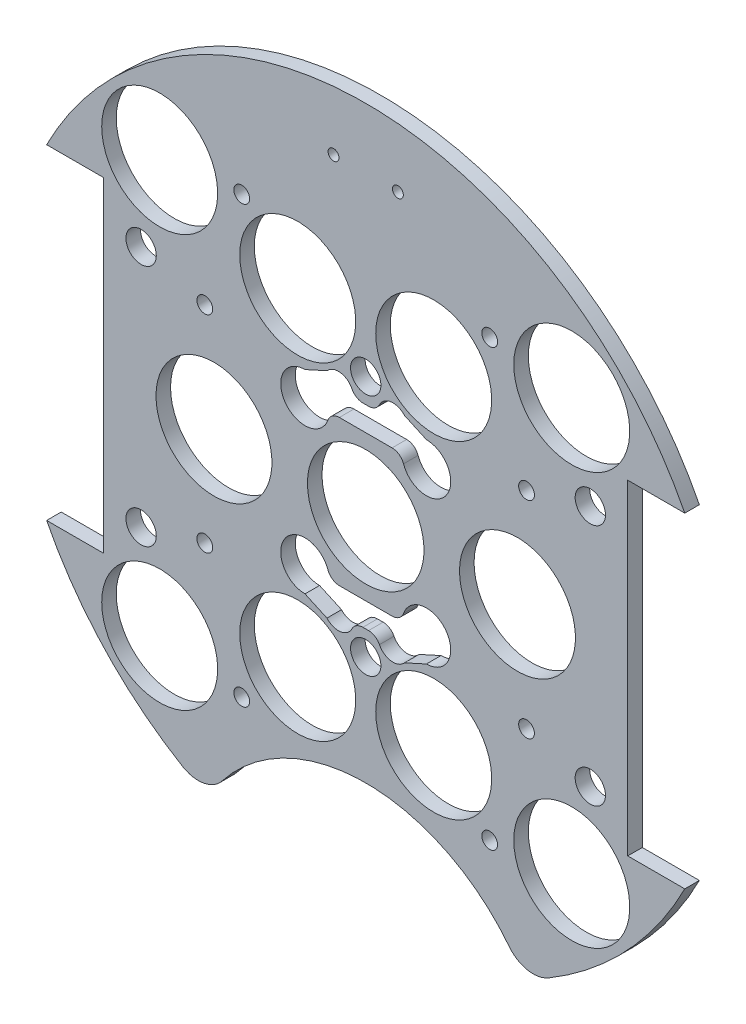
from build123d import *

# Parameters (mm, degrees)
BOSS_EXTRUDE2_DEPTH      = 3.048
SKETCH2_R                = 1.143
CUT_EXTRUDE1_DEPTH       = 101.398460187
SKETCH4_R                = 38.1
CUT_EXTRUDE3_DEPTH       = 124.46
FILLET1_R                = 6.35
SKETCH12_R               = 1.651
CUT_EXTRUDE11_DEPTH      = 75.692
SKETCH14_R               = 1.651
CUT_EXTRUDE13_DEPTH      = 97.79
SKETCH15_R               = 3.175
CUT_EXTRUDE14_DEPTH      = 103.378
CUT_EXTRUDE14_DEPTH_BACK = 48.768
SKETCH3_R                = 12.1285
SKETCH3_R_2              = 12.192
CUT_EXTRUDE2_DEPTH       = 101.398460332
FILLET2_R                = 2.54


with BuildPart() as part:
    # Sketch1 → Boss-Extrude2 (new body)
    with BuildSketch(Plane.XY):
        with BuildLine():
            Line((-66.753693561, 34.036), (-54.815693561, 34.036))
            Line((-54.815693561, 34.036), (-54.815693561, -34.036))
            Line((-54.815693561, -34.036), (-66.753693561, -34.036))
            ThreePointArc((-66.753693561, -34.036), (0, -74.93), (66.753693561, -34.036))
            Line((66.753693561, -34.036), (54.815693561, -34.036))
            Line((54.815693561, -34.036), (54.815693561, 34.036))
            Line((54.815693561, 34.036), (66.753693561, 34.036))
            ThreePointArc((66.753693561, 34.036), (0, 74.93), (-66.753693561, 34.036))
        make_face()
    extrude(amount=BOSS_EXTRUDE2_DEPTH)

    # Sketch2 → Cut-Extrude1 (cut, through all)
    with BuildSketch(Plane.XY.offset(3.048)):
        with Locations((-6.731, 62.23)):
            Circle(SKETCH2_R)
        with Locations((6.731, 62.23)):
            Circle(SKETCH2_R)
    extrude(amount=-CUT_EXTRUDE1_DEPTH, mode=Mode.SUBTRACT)

    # Sketch4 → Cut-Extrude3 (cut)
    with BuildSketch(Plane(origin=(0, 0, 0), x_dir=(-1, 0, 0), z_dir=(0, 0, -1))):
        with Locations((0, -86.312058398)):
            Circle(SKETCH4_R)
    extrude(amount=-CUT_EXTRUDE3_DEPTH, mode=Mode.SUBTRACT)

    # Fillet1
    fillet1_edges = [part.edges().sort_by_distance(p)[0] for p in [
        (-33.000960548, -67.271401821, 1.524),
        (33.000960548, -67.271401821, 1.524),
    ]]
    fillet(fillet1_edges, radius=FILLET1_R)

    # Sketch12 → Cut-Extrude11 (cut)
    with BuildSketch(Plane(origin=(30.092005081, 4.08352975, 0), x_dir=(-1, 0, 0), z_dir=(0, 0, -1))):
        with Locations((63.757223581, 17.50647025)):
            Circle(SKETCH12_R)
        with Locations((63.757223581, -25.67352975)):
            Circle(SKETCH12_R)
        with Locations((-3.552776419, -25.67352975)):
            Circle(SKETCH12_R)
        with Locations((-3.552776419, 17.50647025)):
            Circle(SKETCH12_R)
    extrude(amount=-CUT_EXTRUDE11_DEPTH, mode=Mode.SUBTRACT)

    # Sketch14 → Cut-Extrude13 (cut)
    with BuildSketch(Plane(origin=(30.092005081, 4.08352975, -30.0355), x_dir=(-1, 0, 0), z_dir=(0, 0, -1))):
        with Locations(Location((4.154396091, -49.728759131, 0), (0, 0, 180))):
            Circle(SKETCH14_R)
        with Locations(Location((56.02961407, -49.728759131, 0), (0, 0, 180))):
            Circle(SKETCH14_R)
        with Locations(Location((4.154396091, 41.38247025, 0), (0, 0, 180))):
            Circle(SKETCH14_R)
        with Locations(Location((56.02961407, 41.38247025, 0), (0, 0, 180))):
            Circle(SKETCH14_R)
    extrude(amount=-CUT_EXTRUDE13_DEPTH, mode=Mode.SUBTRACT)

    # Sketch15 → Cut-Extrude14 (cut, two sides)
    with BuildSketch(Plane(origin=(30.092005081, 4.08352975, 6.096), x_dir=(-1, 0, 0), z_dir=(0, 0, -1))) as cut_extrude14_sk:
        with Locations(Location((-16.897994919, 21.31647025, 0), (0, 0, 180))):
            Circle(SKETCH15_R)
        with Locations(Location((77.082005081, 21.31647025, 0), (0, 0, 180))):
            Circle(SKETCH15_R)
        with Locations(Location((30.092005081, 21.31647025, 0), (0, 0, 180))):
            Circle(SKETCH15_R)
        with Locations(Location((77.082005081, -29.48352975, 0), (0, 0, 180))):
            Circle(SKETCH15_R)
        with Locations(Location((30.092005081, -29.48352975, 0), (0, 0, 180))):
            Circle(SKETCH15_R)
        with Locations(Location((-16.897994919, -29.48352975, 0), (0, 0, 180))):
            Circle(SKETCH15_R)
    extrude(amount=CUT_EXTRUDE14_DEPTH, mode=Mode.SUBTRACT)
    extrude(cut_extrude14_sk.sketch, amount=-CUT_EXTRUDE14_DEPTH_BACK, mode=Mode.SUBTRACT)

    # Sketch3 → Cut-Extrude2 (cut, through all)
    with BuildSketch(Plane(origin=(0, 0, 0), x_dir=(-1, 0, 0), z_dir=(0, 0, -1))):
        with Locations((-31.75, 0)):
            Circle(SKETCH3_R)
        with Locations((31.75, 0)):
            Circle(SKETCH3_R)
        Circle(SKETCH3_R_2)
        with Locations((-43.105229381, -43.105229381)):
            Circle(SKETCH3_R)
        with Locations((14.224, -34.29)):
            Circle(SKETCH3_R)
        with Locations((14.224, 34.29)):
            Circle(SKETCH3_R)
        with Locations((-43.105229381, 43.105229381)):
            Circle(SKETCH3_R)
        with Locations((43.105229381, 43.105229381)):
            Circle(SKETCH3_R)
        with Locations((-14.224, 34.29)):
            Circle(SKETCH3_R)
        with Locations((-14.224, -34.29)):
            Circle(SKETCH3_R)
        with Locations((43.105229381, -43.105229381)):
            Circle(SKETCH3_R)
        with BuildLine():
            Line((7.62, 15.24), (-7.62, 15.24))
            ThreePointArc((-7.62, 15.24), (-16.292102448, 11.647897552), (-12.7, 20.32))
            Line((-12.7, 20.32), (-8.107123288, 22.407671233))
            ThreePointArc((-8.107123288, 22.407671233), (-4.600183073, 23.292845139), (-2.54, 20.32))
            Line((-2.54, 20.32), (2.54, 20.32))
            ThreePointArc((2.54, 20.32), (4.600183073, 23.292845139), (8.107123288, 22.407671233))
            Line((8.107123288, 22.407671233), (12.7, 20.32))
            ThreePointArc((12.7, 20.32), (16.292102448, 11.647897552), (7.62, 15.24))
        make_face()
        with BuildLine():
            Line((7.62, -15.24), (-7.62, -15.24))
            ThreePointArc((-7.62, -15.24), (-16.292102448, -11.647897552), (-12.7, -20.32))
            Line((-12.7, -20.32), (-8.107123288, -22.407671233))
            ThreePointArc((-8.107123288, -22.407671233), (-4.600183073, -23.292845139), (-2.54, -20.32))
            Line((-2.54, -20.32), (2.54, -20.32))
            ThreePointArc((2.54, -20.32), (4.600183073, -23.292845139), (8.107123288, -22.407671233))
            Line((8.107123288, -22.407671233), (12.7, -20.32))
            ThreePointArc((12.7, -20.32), (16.292102448, -11.647897552), (7.62, -15.24))
        make_face()
    extrude(amount=-CUT_EXTRUDE2_DEPTH, mode=Mode.SUBTRACT)

    # Fillet2
    fillet2_edges = [part.edges().sort_by_distance(p)[0] for p in [
        (-7.62, -15.24, 1.524),
        (-2.54, -20.32, 1.524),
        (2.54, -20.32, 1.524),
        (7.62, -15.24, 1.524),
        (-7.62, 15.24, 1.524),
        (7.62, 15.24, 1.524),
        (2.54, 20.32, 1.524),
        (-2.54, 20.32, 1.524),
    ]]
    fillet(fillet2_edges, radius=FILLET2_R)


solid = part.part
